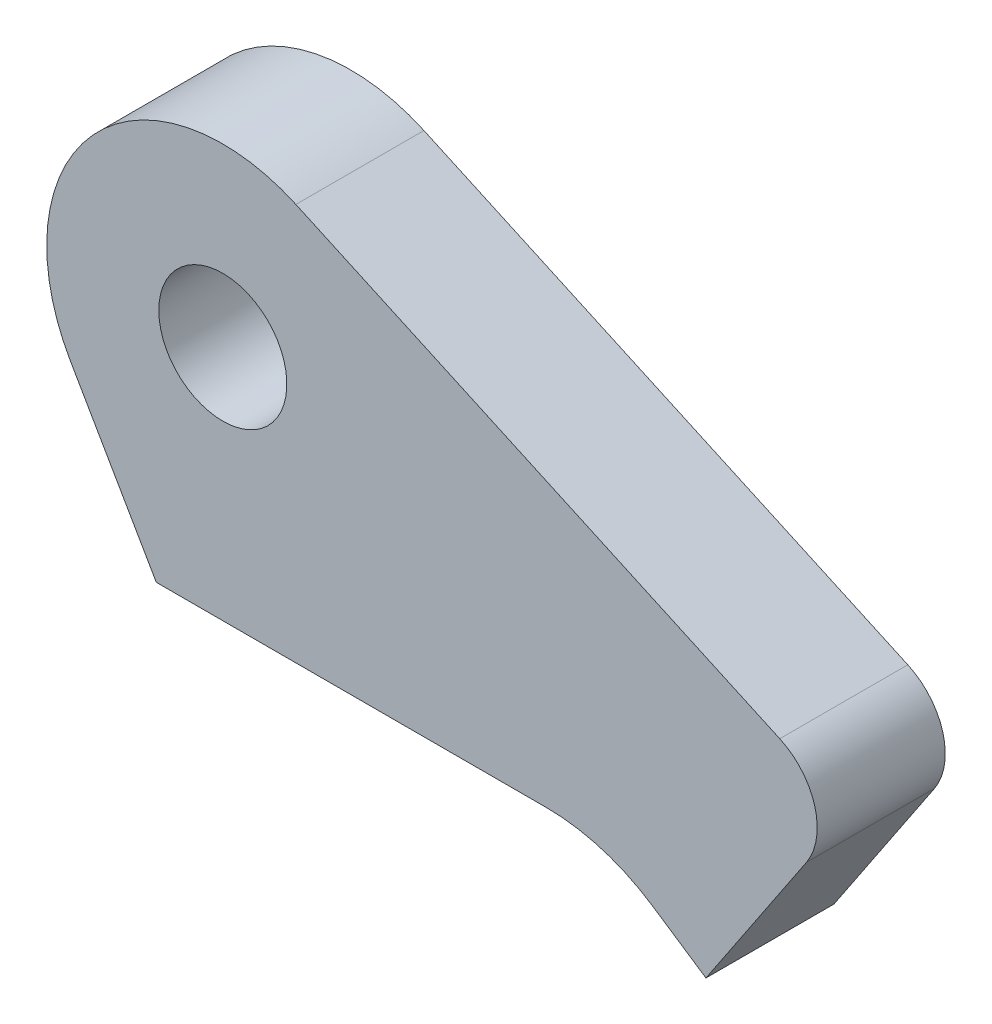
from build123d import *

# Parameters (mm, degrees)
BASE_EXTRUDE_DEPTH = 10
SKETCH2_R          = 5
CUT_EXTRUDE1_DEPTH = 11
FILLET1_R          = 5


with BuildPart() as part:
    # Sketch1 → Base-Extrude (new body)
    with BuildSketch(Plane.XY):
        with BuildLine():
            Line((17.145241183, 27.717792456), (28.25998861, 44.344950651))
            Line((28.25998861, 44.344950651), (-14.878235452, 64.026276153))
            ThreePointArc((-14.878235452, 64.026276153), (-30.761612778, 60.763930789), (-32.493423944, 44.641728625))
            Line((-32.493423944, 44.641728625), (-25.781727065, 33.016728625))
            Line((-25.781727065, 33.016728625), (4.666426174, 33.016728625))
            ThreePointArc((4.666426174, 33.016728625), (9.022139107, 32.370395921), (13.002486744, 30.487097271))
            Line((13.002486744, 30.487097271), (17.145241183, 27.717792456))
        make_face()
    extrude(amount=-BASE_EXTRUDE_DEPTH)

    # Sketch2 → Cut-Extrude1 (cut, through all)
    with BuildSketch(Plane(origin=(0, 0, -10), x_dir=(-1, 0, 0), z_dir=(0, 0, -1))):
        with Locations((20.585574642, 51.516728625)):
            Circle(SKETCH2_R)
    extrude(amount=-CUT_EXTRUDE1_DEPTH, mode=Mode.SUBTRACT)

    # Fillet1
    fillet1_edges = [part.edges().sort_by_distance(p)[0] for p in [
        (28.25998861, 44.344950651, -5),
    ]]
    fillet(fillet1_edges, radius=FILLET1_R)


solid = part.part
